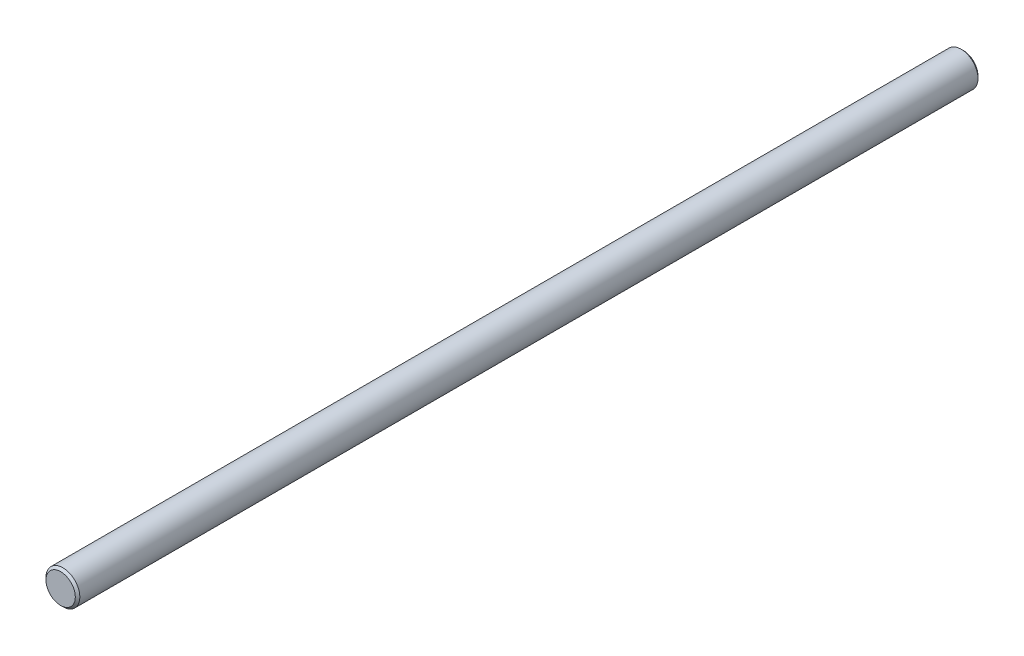
from build123d import *

# Parameters (mm, degrees)
SKETCH1_R           = 4.7625
BOSS_EXTRUDE1_DEPTH = 254
CHAMFER1_SIZE       = 0.635


with BuildPart() as part:
    # Sketch1 → Boss-Extrude1 (new body)
    with BuildSketch(Plane.XY):
        Circle(SKETCH1_R)
    extrude(amount=BOSS_EXTRUDE1_DEPTH)

    # Chamfer1
    chamfer1_edges = [part.edges().sort_by_distance(p)[0] for p in [
        (-4.7625, 0, 0),
        (-4.7625, 0, 254),
    ]]
    chamfer(chamfer1_edges, length=CHAMFER1_SIZE)


solid = part.part
